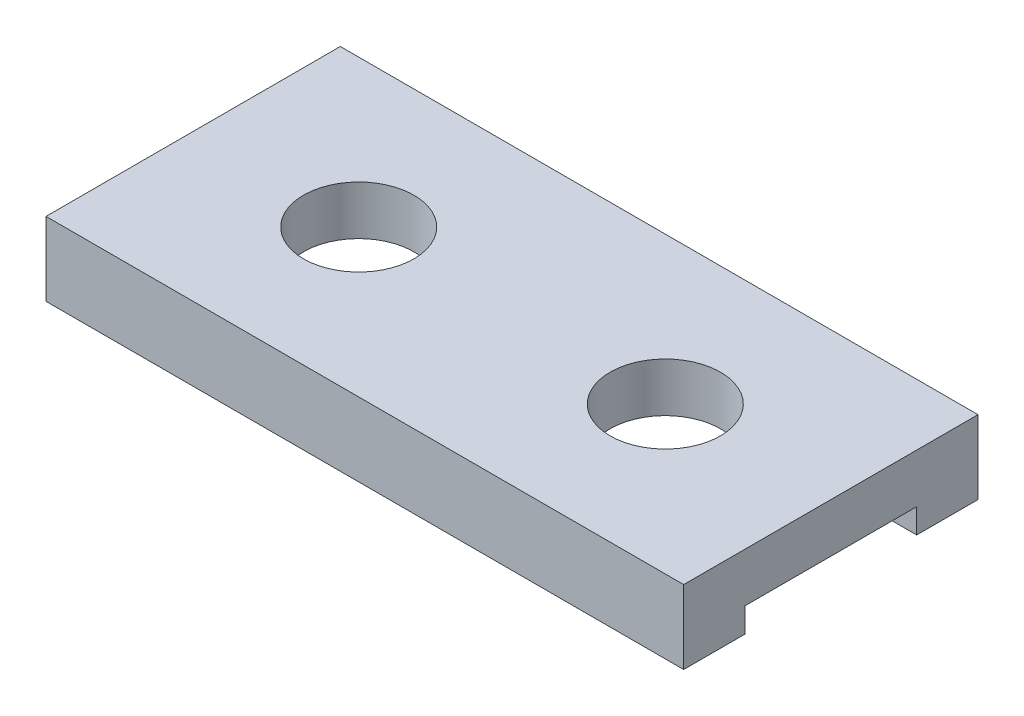
from build123d import *

# Parameters (mm, degrees)
SKETCH1_W      = 26
SKETCH1_H      = 12
EXTRUDE1_DEPTH = 3
SKETCH2_R      = 2.25
EXTRUDE2_DEPTH = 4
SKETCH3_W      = 7
SKETCH3_H      = 1
EXTRUDE3_DEPTH = 27


with BuildPart() as part:
    # Sketch1 → Extrude1 (new body)
    with BuildSketch(Plane(origin=(0, 0, 0), x_dir=(1, 0, 0), z_dir=(0, 1, 0))):
        Rectangle(SKETCH1_W, SKETCH1_H)
    extrude(amount=-EXTRUDE1_DEPTH)

    # Sketch2 → Extrude2 (cut, through all)
    with BuildSketch(Plane(origin=(0, 0, 0), x_dir=(1, 0, 0), z_dir=(0, 1, 0))):
        with Locations(Location((-6.25, 0, 0), (0, 0, 270))):  # turned: the seam where the file's is
            Circle(SKETCH2_R)
        with Locations(Location((6.25, 0, 0), (0, 0, 270))):  # turned: the seam where the file's is
            Circle(SKETCH2_R)
    extrude(amount=-EXTRUDE2_DEPTH, mode=Mode.SUBTRACT)

    # Sketch3 → Extrude3 (cut, through all)
    with BuildSketch(Plane(origin=(13, 0, 0), x_dir=(0, 0, -1), z_dir=(1, 0, 0))):
        with Locations((0, -2.5)):
            Rectangle(SKETCH3_W, SKETCH3_H)
    extrude(amount=-EXTRUDE3_DEPTH, mode=Mode.SUBTRACT)


solid = part.part
